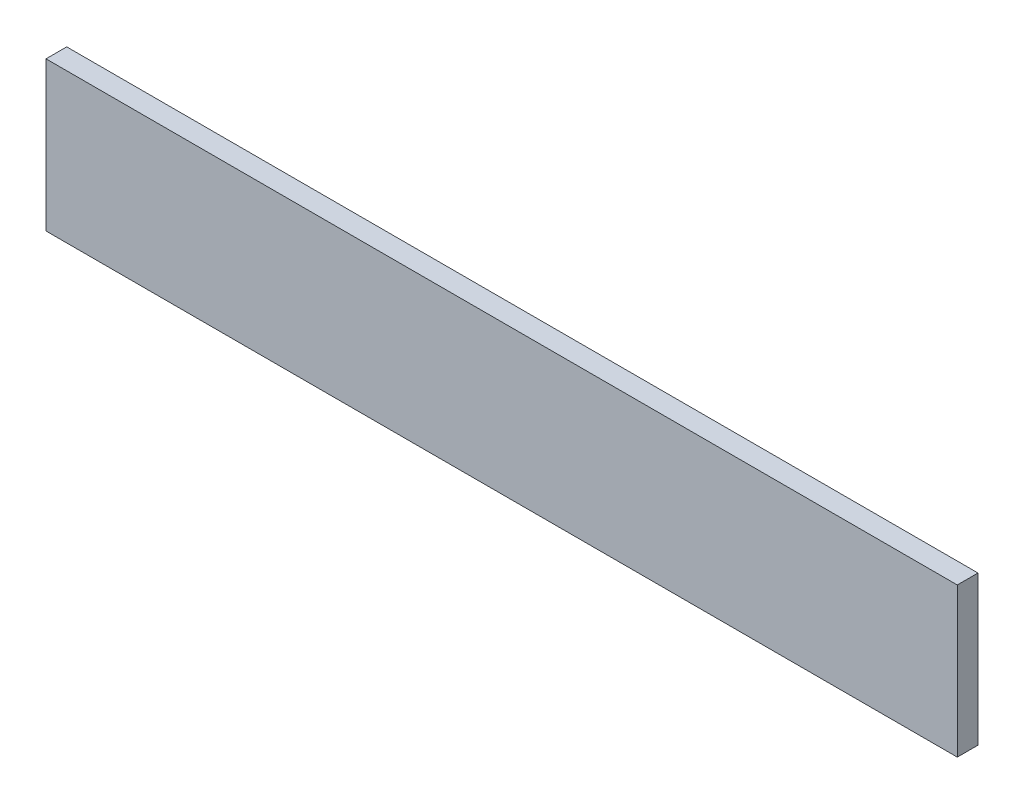
from build123d import *

# Parameters (mm, degrees)
SKETCH1_W           = 139.7
SKETCH1_H           = 22.86
BOSS_EXTRUDE1_DEPTH = 1.5875


with BuildPart() as part:
    # Sketch1 → Boss-Extrude1 (new body, symmetric)
    with BuildSketch(Plane.XY):
        Rectangle(SKETCH1_W, SKETCH1_H)
    extrude(amount=BOSS_EXTRUDE1_DEPTH, both=True)


solid = part.part
